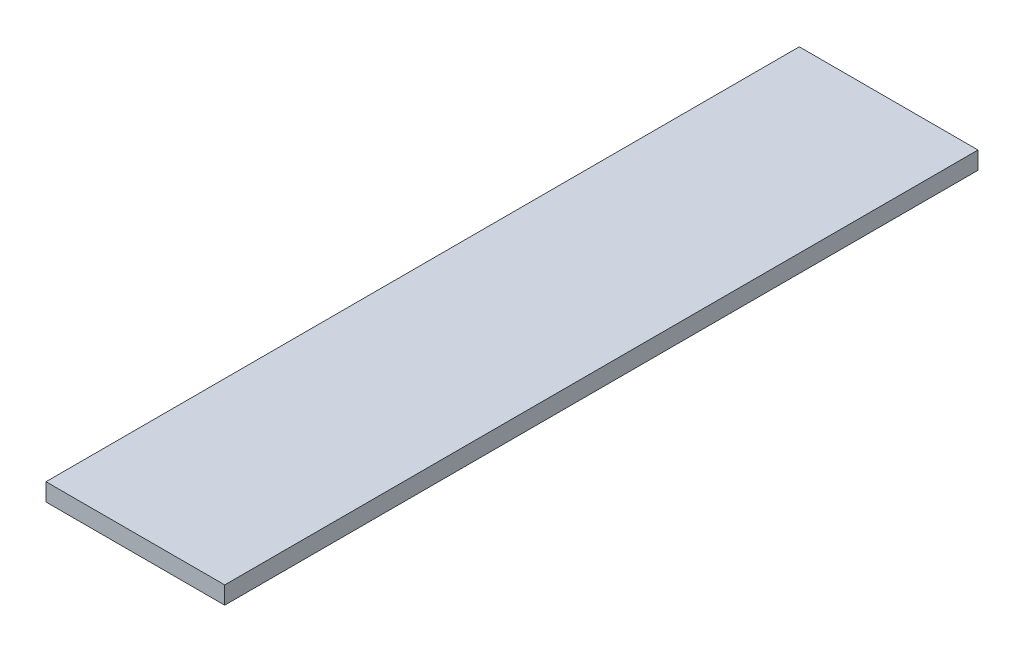
from build123d import *

# Parameters (mm, degrees)
SKETCH1_W           = 50.8
SKETCH1_H           = 5
BOSS_EXTRUDE1_DEPTH = 214.122


with BuildPart() as part:
    # Sketch1 → Boss-Extrude1 (new body)
    with BuildSketch(Plane.XY):
        Rectangle(SKETCH1_W, SKETCH1_H)
    extrude(amount=BOSS_EXTRUDE1_DEPTH)


solid = part.part
